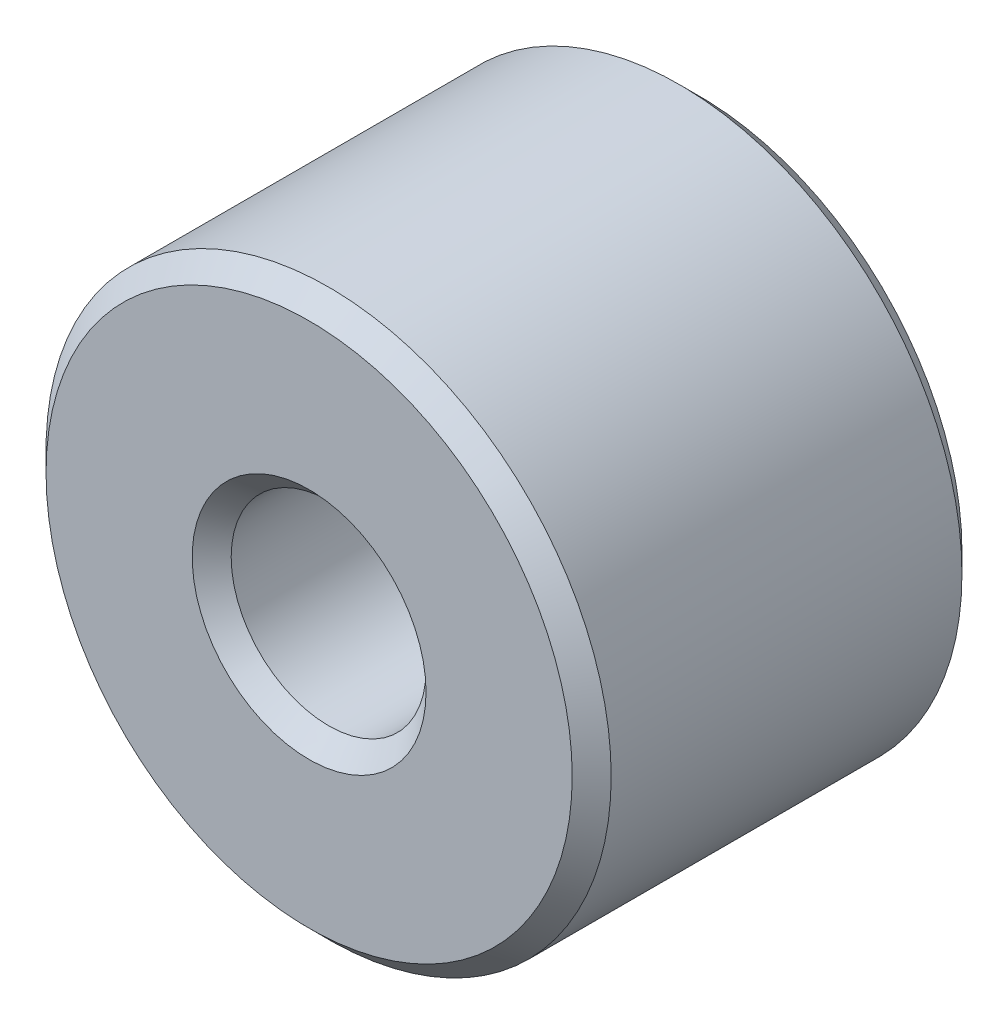
from build123d import *

# Parameters (mm, degrees)
SKETCH1_R           = 7.25
SKETCH1_R_2         = 2.5
BOSS_EXTRUDE1_DEPTH = 10
CHAMFER1_SIZE       = 0.5


with BuildPart() as part:
    # Sketch1 → Boss-Extrude1 (new body)
    with BuildSketch(Plane.XY):
        Circle(SKETCH1_R)
        Circle(SKETCH1_R_2, mode=Mode.SUBTRACT)
    extrude(amount=BOSS_EXTRUDE1_DEPTH)

    # Chamfer1
    chamfer1_edges = [part.edges().sort_by_distance(p)[0] for p in [
        (-7.25, 0, 0),
        (-7.25, 0, 10),
        (-2.5, 0, 0),
        (-2.5, 0, 10),
    ]]
    chamfer(chamfer1_edges, length=CHAMFER1_SIZE)


solid = part.part
